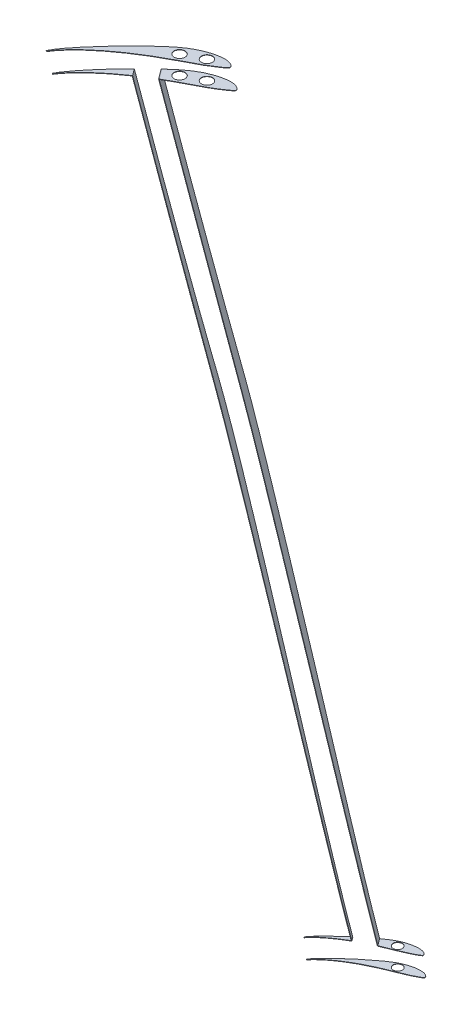
from build123d import *

# Parameters (mm, degrees)
DODANIE_WYCI_GNI_CIE1_DEPTH   = 0.2
DODANIE_WYCI_GNI_CIE2_DEPTH   = 0.2
DODANIE_WYCI_GNI_CIE2_2_DEPTH = 0.2
DODANIE_WYCI_GNI_CIE3_DEPTH   = 0.2
DODANIE_WYCI_GNI_CIE4_DEPTH   = 0.2
DODANIE_WYCI_GNI_CIE5_DEPTH   = 0.2
DODANIE_WYCI_GNI_CIE6_DEPTH   = 0.2
SZKIC7_R                      = 3
WYTNIJ_WYCI_GNI_CIE1_DEPTH    = 12
SZKIC8_R                      = 2.5
WYTNIJ_WYCI_GNI_CIE2_DEPTH    = 12


with BuildPart() as part:
    # Szkic1 → Dodanie-wyciągnięcie1 (new body)
    with BuildSketch(Plane(origin=(0, 700, 0), x_dir=(1, 0, 0), z_dir=(0, 1, 0))):
        with BuildLine():
            Line((-469.151161363, -367.543387188), (-468.754033275, -367.809994573))
            add(Edge.make_bspline(
                [(-468.754033275, -367.809994573), (-468.569338946, -367.494480307), (-468.01155972, -366.60097334), (-466.947424283, -365.122962709), (-465.48428441, -363.306139265), (-463.756300353, -361.359608702), (-461.777561527, -359.314012567), (-459.570064428, -357.20075631), (-457.1553099, -355.05105778), (-454.562230798, -352.890898878), (-451.819856998, -350.745854133), (-448.95930951, -348.639188908), (-446.014833296, -346.589685169), (-443.021070748, -344.613837909), (-440.011073093, -342.727663318), (-437.021704481, -340.938294995), (-434.085422118, -339.25475988), (-431.236177714, -337.680608934), (-428.504481226, -336.21740308), (-425.920558568, -334.863007757), (-423.512367554, -333.611067876), (-421.298114193, -332.459548251), (-419.301271715, -331.358918227), (-417.520296457, -330.293454547), (-415.926643183, -329.300954093), (-414.524688112, -328.390558609), (-413.329960462, -327.570084414), (-412.346413436, -326.860502064), (-411.611043021, -326.237035452), (-411.079804142, -325.773282415), (-410.822961265, -325.253136108), (-411.023332484, -324.771728189), (-411.343648226, -324.327208866), (-411.841838716, -323.895894334), (-412.480332279, -323.506517601), (-413.256323012, -323.178089215), (-414.157747518, -322.922405377), (-415.18757912, -322.771643728), (-416.339089793, -322.728838316), (-417.6073415, -322.779706179), (-418.982209878, -322.936393076), (-420.451786837, -323.202080709), (-422.005498651, -323.578591502), (-423.631299627, -324.073668443), (-425.319415007, -324.683819216), (-427.055948123, -325.414961207), (-428.829361223, -326.269310885), (-430.623405456, -327.264272721), (-432.43901635, -328.399450027), (-434.269608687, -329.697174829), (-436.121612028, -331.150700732), (-438.019015215, -332.722539148), (-439.944328295, -334.414483906), (-441.895976558, -336.205544225), (-443.868637062, -338.078106566), (-445.856001638, -340.009413128), (-447.843745434, -341.981365329), (-449.818738609, -343.973423903), (-451.762014358, -345.973691397), (-453.658579771, -347.968842865), (-455.496647581, -349.945626121), (-457.262175947, -351.893988144), (-458.946910466, -353.800266685), (-460.538876427, -355.654188103), (-462.030647352, -357.4425374), (-463.412826785, -359.154757791), (-464.677262961, -360.78053458), (-465.817166352, -362.309964072), (-466.827364143, -363.733180553), (-467.701923622, -365.042564021), (-468.437355931, -366.229984791), (-468.89927664, -367.054105831), (-469.118218662, -367.478463201), (-469.151161363, -367.543387188)],
                knots=[0.021882554, 0.021882554, 0.021882554, 0.021882554, 0.028864178, 0.04183079, 0.056713807, 0.073341232, 0.091507989, 0.111021837, 0.131661709, 0.153207715, 0.175433402, 0.198110317, 0.221011446, 0.243905882, 0.266573311, 0.288810349, 0.310405036, 0.331177743, 0.350943876, 0.3695564, 0.386864963, 0.402753039, 0.417195876, 0.430379519, 0.442362633, 0.453032156, 0.462284346, 0.470026206, 0.476176645, 0.480649947, 0.483553073, 0.486420689, 0.489953231, 0.494096927, 0.498850588, 0.50419675, 0.510125492, 0.516691031, 0.524011699, 0.532092122, 0.540897921, 0.550403414, 0.560581041, 0.571396483, 0.582828081, 0.594829641, 0.607347037, 0.620384325, 0.633968937, 0.648199967, 0.663193937, 0.678898581, 0.695226562, 0.712113221, 0.729459406, 0.747143117, 0.765009772, 0.782904928, 0.800688045, 0.818242105, 0.835449083, 0.852211621, 0.868429578, 0.884009363, 0.898854951, 0.912881827, 0.92601075, 0.938166771, 0.949289699, 0.959322172, 0.968216949, 0.97594822, 0.977339045, 0.977339045, 0.977339045, 0.977339045], degree=3))
        make_face()
    extrude(amount=DODANIE_WYCI_GNI_CIE1_DEPTH)


with BuildPart() as body_2:
    # Szkic2 → Dodanie-wyciągnięcie2 (new body)
    with BuildSketch(Plane.XZ.offset(-690)):
        with BuildLine():
            Line((-435.154658869, 340.113629547), (-439.167847926, 334.704926055))
            add(Edge.make_bspline(
                [(-439.167847926, 334.704926055), (-438.674884138, 334.248735131), (-437.54704616, 333.219166125), (-435.781759067, 331.66785051), (-433.88435588, 330.096012093), (-432.032352538, 328.642486191), (-430.201760202, 327.344761389), (-428.386149308, 326.209584083), (-426.592105074, 325.214622247), (-424.818691974, 324.360272569), (-423.082158858, 323.629130578), (-421.394043479, 323.018979805), (-419.768242503, 322.523902864), (-418.214530689, 322.147392071), (-416.74495373, 321.881704438), (-415.370085351, 321.72501754), (-414.101833645, 321.674149678), (-412.950322972, 321.71695509), (-411.92049137, 321.867716739), (-411.019066863, 322.123400577), (-410.24307613, 322.451828963), (-409.604582568, 322.841205696), (-409.106392077, 323.272520228), (-408.786076335, 323.717039551), (-408.585705116, 324.19844747), (-408.842547994, 324.718593777), (-409.373786872, 325.182346814), (-410.109157287, 325.805813425), (-411.092704313, 326.515395776), (-412.287431964, 327.335869971), (-413.689387035, 328.246265454), (-415.283040308, 329.238765908), (-417.064015567, 330.304229588), (-419.060858044, 331.404859613), (-421.275111405, 332.556379238), (-423.68330242, 333.808319119), (-426.267225078, 335.162714442), (-428.998921566, 336.625920296), (-431.84816597, 338.200071242), (-433.909500044, 339.381949505), (-435.019864192, 340.034212856), (-435.154658869, 340.113629547)],
                knots=[0.276246459, 0.276246459, 0.276246459, 0.276246459, 0.2896648, 0.306753994, 0.323190791, 0.338883781, 0.353778265, 0.367996193, 0.381641281, 0.394742239, 0.407303314, 0.419267854, 0.430587514, 0.441239623, 0.451188263, 0.460404589, 0.468861723, 0.476523682, 0.483395307, 0.489600448, 0.495195848, 0.500171126, 0.504508001, 0.508205231, 0.511206535, 0.514245006, 0.518926854, 0.525364027, 0.533466814, 0.543150343, 0.554317279, 0.566859048, 0.580657314, 0.595773478, 0.612402258, 0.630517749, 0.649997991, 0.670685624, 0.692426757, 0.715028191, 0.718153736, 0.718153736, 0.718153736, 0.718153736], degree=3))
        make_face()
    extrude(amount=DODANIE_WYCI_GNI_CIE2_DEPTH)

    # Szkic3 → Dodanie-wyciągnięcie3 (add)
    with BuildSketch(Plane(origin=(-295.538450961, -87.183744061, 219.285763923), x_dir=(-0.556130606, -0.164058343, -0.814741437), z_dir=(0.781447989, 0.230526895, -0.579824448))):
        with BuildLine():
            Line((-112.442125967, 394.872681615), (-107.718471353, 395.680653374))
            add(Edge.make_bspline(
                [(-107.718471353, 395.680653374), (-107.995832024, 398.253393679), (-108.238299162, 400.829867367), (-108.67795625, 405.986010422), (-108.874839994, 408.565753226), (-109.417055788, 416.308509628), (-109.714877053, 421.475250205), (-110.239678221, 431.810932285), (-110.465762991, 436.980376597), (-110.875867202, 447.321122325), (-111.059642421, 452.492479146), (-111.577463194, 468.007698082), (-111.877160695, 478.352606755), (-112.483789549, 499.04219693), (-112.79623359, 509.386705314), (-113.507724269, 530.073002441), (-113.904225496, 540.414679246), (-114.797102632, 561.093244077), (-115.292539721, 571.430324858), (-116.143336846, 586.931109411), (-116.44503699, 592.096885696), (-117.100310928, 602.423657951), (-117.453301541, 607.584877215), (-118.245916642, 617.899911535), (-118.683775285, 623.053877509), (-119.469311859, 630.773822903), (-119.752977362, 633.345273179), (-120.388567669, 638.482339913), (-120.739939712, 641.048851858), (-121.149091713, 643.608528228)],
                knots=[0, 0, 0, 0, 0.03125, 0.03125, 0.0625, 0.0625, 0.125, 0.125, 0.1875, 0.1875, 0.25, 0.25, 0.375, 0.375, 0.5, 0.5, 0.625, 0.625, 0.75, 0.75, 0.8125, 0.8125, 0.875, 0.875, 0.9375, 0.9375, 0.96875, 0.96875, 1, 1, 1, 1], degree=3))
            add(Edge.make_bspline(
                [(-121.149091713, 643.608528228), (-122.095771837, 649.531008733), (-123.089876294, 655.445754322), (-125.057115479, 667.278665745), (-126.028548204, 673.197108951), (-127.925338173, 685.041509574), (-128.851842631, 690.967368454), (-130.651895828, 702.826505572), (-131.52564263, 708.759876065), (-134.071818525, 726.57084723), (-135.668556223, 738.45978396), (-138.735293735, 762.253240837), (-140.206473336, 774.157850311), (-141.66354734, 786.064245496)],
                knots=[0, 0, 0, 0, 0.125, 0.125, 0.25, 0.25, 0.375, 0.375, 0.5, 0.5, 0.75, 0.75, 1, 1, 1, 1], degree=3))
            Line((-141.66354734, 786.064245496), (-148.302099459, 784.928734314))
            add(Edge.make_bspline(
                [(-148.302099459, 784.928734314), (-146.832383128, 773.019362902), (-145.358308533, 761.110523026), (-142.37255026, 737.29759311), (-140.860193161, 725.393562292), (-137.781332039, 701.592416698), (-136.214224644, 689.695469489), (-133.0441377, 665.906298442), (-131.444516851, 654.013665882), (-129.847452676, 642.120690825)],
                knots=[0, 0, 0, 0, 0.25, 0.25, 0.5, 0.5, 0.75, 0.75, 1, 1, 1, 1], degree=3))
            add(Edge.make_bspline(
                [(-129.847452676, 642.120690825), (-129.503753749, 639.561242795), (-129.188650323, 636.997967653), (-128.596621984, 631.867485224), (-128.31993079, 629.300222852), (-127.531866207, 621.594041649), (-127.061749034, 616.450630518), (-126.187316499, 606.158828011), (-125.78365027, 601.010008903), (-125.019730162, 590.709286705), (-124.659688805, 585.557284875), (-123.623105696, 570.098505967), (-122.989084596, 559.789213033), (-121.764302264, 539.168017712), (-121.174295808, 528.856069798), (-119.409057697, 497.91993765), (-118.243545309, 477.29518149), (-116.322492612, 446.368224554), (-115.653955933, 436.06115909), (-114.556241661, 420.607638325), (-114.174285055, 415.457643999), (-113.358077566, 405.161497191), (-112.925292657, 400.015170506), (-112.442125967, 394.872681615)],
                knots=[0, 0, 0, 0, 0.03125, 0.03125, 0.0625, 0.0625, 0.125, 0.125, 0.1875, 0.1875, 0.25, 0.25, 0.375, 0.375, 0.5, 0.5, 0.75, 0.75, 0.875, 0.875, 0.9375, 0.9375, 1, 1, 1, 1], degree=3))
        make_face()
    extrude(amount=DODANIE_WYCI_GNI_CIE3_DEPTH)



with BuildPart() as body_3:
    # Szkic2 → Dodanie-wyci_gni_cie2 2 (new body)
    with BuildSketch(Plane.XZ.offset(-690)):
        with BuildLine():
            Line((-466.516777127, 366.755305935), (-466.913905214, 366.488698548))
            add(Edge.make_bspline(
                [(-466.913905214, 366.488698548), (-466.880962514, 366.423774563), (-466.662020492, 365.999417193), (-466.200099782, 365.175296153), (-465.464667474, 363.987875383), (-464.590107995, 362.678491915), (-463.579910203, 361.255275433), (-462.440006812, 359.725845942), (-461.175570637, 358.100069153), (-459.793391203, 356.387848762), (-458.301620279, 354.599499465), (-456.709654318, 352.745578047), (-455.024919798, 350.839299506), (-453.259391433, 348.890937483), (-451.421323622, 346.914154226), (-449.524758209, 344.919002759), (-447.910501795, 343.257403968), (-446.929508181, 342.262846842), (-446.601978671, 341.932309257)],
                knots=[0.787204945, 0.787204945, 0.787204945, 0.787204945, 0.788660611, 0.796752314, 0.806061767, 0.816561955, 0.828203436, 0.840926173, 0.854667168, 0.869347978, 0.88488567, 0.901191786, 0.918165827, 0.935709836, 0.953719006, 0.972091438, 0.990703606, 1, 1, 1, 1], degree=3))
            Line((-446.601978671, 341.932309257), (-443.86934511, 345.615167074))
            add(Edge.make_bspline(
                [(-443.86934511, 345.615167074), (-444.828451589, 346.266480341), (-446.754610912, 347.608477449), (-449.582600849, 349.691165494), (-452.324974648, 351.83621024), (-454.91805375, 353.996369141), (-457.332808278, 356.146067671), (-459.540305377, 358.259323928), (-461.519044203, 360.304920063), (-463.24702826, 362.251450626), (-464.710168134, 364.06827407), (-465.77430357, 365.546284701), (-466.332082797, 366.439791668), (-466.516777127, 366.755305935)],
                knots=[0, 0, 0, 0, 0.023161092, 0.046895208, 0.070157059, 0.092707542, 0.114309649, 0.134733235, 0.153746928, 0.171149526, 0.186726392, 0.200297508, 0.207604617, 0.207604617, 0.207604617, 0.207604617], degree=3))
        make_face()
    extrude(amount=DODANIE_WYCI_GNI_CIE2_2_DEPTH)

    # Szkic4 → Dodanie-wyciągnięcie4 (add)
    with BuildSketch(Plane(origin=(-303.352930853, -89.489013012, 225.084008406), x_dir=(0.556130606, 0.164058343, 0.814741437), z_dir=(-0.781447989, -0.230526895, 0.579824448))):
        with BuildLine():
            Line((108.446658466, 397.959582923), (111.045839487, 397.51499816))
            add(Edge.make_bspline(
                [(111.045839487, 397.51499816), (111.58979421, 402.650382191), (112.05601068, 407.793594665), (112.915080215, 418.085437745), (113.305872608, 423.234759559), (114.412789535, 438.686625286), (115.065386645, 448.99367813), (116.313905542, 469.61138001), (116.907428868, 479.922029793), (118.082241993, 500.544045332), (118.662240544, 510.855488289), (119.841616113, 531.477235249), (120.440536199, 541.787565953), (121.695403243, 562.404874697), (122.350314973, 572.712406625), (123.423819809, 588.165342163), (123.797110403, 593.314949533), (124.589836796, 603.610070519), (125.008988108, 608.755609372), (125.919080095, 619.040318311), (126.409129838, 624.179567436), (127.236645578, 631.880240242), (127.528129305, 634.445743223), (128.155505556, 639.572809476), (128.491109132, 642.134398381), (128.860521569, 644.692987946)],
                knots=[0, 0, 0, 0, 0.0625, 0.0625, 0.125, 0.125, 0.25, 0.25, 0.375, 0.375, 0.5, 0.5, 0.625, 0.625, 0.75, 0.75, 0.8125, 0.8125, 0.875, 0.875, 0.9375, 0.9375, 0.96875, 0.96875, 1, 1, 1, 1], degree=3))
            add(Edge.make_bspline(
                [(128.860521569, 644.692987946), (130.575018089, 656.567771978), (132.292298934, 668.442182604), (135.643978804, 692.202600773), (137.27940195, 704.088562506), (140.451342293, 727.873887776), (141.988954677, 739.772879209), (144.998881272, 763.579280151), (146.472053105, 775.486440486), (147.937926308, 787.39450992)],
                knots=[0, 0, 0, 0, 0.25, 0.25, 0.5, 0.5, 0.75, 0.75, 1, 1, 1, 1], degree=3))
            Line((147.937926308, 787.39450992), (143.417648279, 788.167694518))
            add(Edge.make_bspline(
                [(143.417648279, 788.167694518), (141.963050275, 776.260996647), (140.49239967, 764.3562302), (137.408688945, 740.565180301), (135.795100136, 728.678267924), (132.325170785, 704.941406679), (130.467099897, 693.089983365), (127.44840839, 675.352897183), (126.403853227, 669.447434779), (124.238926554, 657.650159322), (123.118283821, 651.758395097), (121.9710178, 645.871423911)],
                knots=[0, 0, 0, 0, 0.25, 0.25, 0.5, 0.5, 0.75, 0.75, 0.875, 0.875, 1, 1, 1, 1], degree=3))
            add(Edge.make_bspline(
                [(121.9710178, 645.871423911), (121.475535527, 643.328953542), (121.042433033, 640.774399619), (120.259708, 635.654790265), (119.910485012, 633.089523936), (118.952140344, 625.38214774), (118.430318328, 620.227489721), (117.520167335, 609.914551059), (117.13326902, 604.754075032), (116.446958941, 594.42798149), (116.148145568, 589.262328809), (115.344507216, 573.75991691), (114.931253878, 563.417776128), (114.233483239, 542.725928893), (113.950758433, 532.37794103), (113.436173403, 511.680996237), (113.204884908, 501.331852392), (112.710102732, 480.634396271), (112.448415114, 470.285883909), (111.956771623, 454.766575867), (111.776193719, 449.594049436), (111.362961819, 439.250793859), (111.130623024, 434.079636118), (110.583482312, 423.743730723), (110.26970603, 418.578685907), (109.692372304, 410.838833511), (109.481888975, 408.26018736), (109.009484647, 403.106615274), (108.747974655, 400.531659612), (108.446658466, 397.959582923)],
                knots=[0, 0, 0, 0, 0.03125, 0.03125, 0.0625, 0.0625, 0.125, 0.125, 0.1875, 0.1875, 0.25, 0.25, 0.375, 0.375, 0.5, 0.5, 0.625, 0.625, 0.75, 0.75, 0.8125, 0.8125, 0.875, 0.875, 0.9375, 0.9375, 0.96875, 0.96875, 1, 1, 1, 1], degree=3))
        make_face()
    extrude(amount=DODANIE_WYCI_GNI_CIE4_DEPTH)


with BuildPart() as body_4:
    # Szkic5 → Dodanie-wyciągnięcie5 (new body)
    with BuildSketch(Plane.XZ.offset(-300)):
        with BuildLine():
            Line((-367.723499777, 326.620936737), (-367.965351577, 326.4188966))
            add(Edge.make_bspline(
                [(-367.965351577, 326.4188966), (-367.939295152, 326.378624781), (-367.766611838, 326.115648761), (-367.40718925, 325.607466751), (-366.843532329, 324.880073971), (-366.180314976, 324.082348287), (-365.420383088, 323.219376286), (-364.568148768, 322.295742292), (-363.62768086, 321.317554434), (-362.604110155, 320.290834383), (-361.503488334, 319.221779302), (-360.332699316, 318.116659259), (-359.097519286, 316.983621746), (-357.80650203, 315.828573745), (-356.465997019, 314.659898786), (-355.085897303, 313.483216933), (-353.674838973, 312.306399727), (-352.243563583, 311.137145617), (-350.805318217, 309.981944032), (-349.370120515, 308.853348808), (-347.948603047, 307.762232258), (-346.546466438, 306.723071676), (-345.168411478, 305.747041504), (-343.81691557, 304.847787204), (-342.503315217, 304.022928897), (-341.214473839, 303.298682511), (-339.946643169, 302.679911317), (-338.702600112, 302.151529061), (-337.481758999, 301.713860097), (-336.293568044, 301.354381364), (-335.145434553, 301.070845971), (-334.046056599, 300.858419598), (-333.002079463, 300.718717367), (-332.02086267, 300.645836232), (-331.109208997, 300.637853882), (-330.274701932, 300.691865468), (-329.523138866, 300.799215406), (-328.858739016, 300.968922332), (-328.285701877, 301.198534883), (-327.799863209, 301.467173885), (-327.408315002, 301.766279262), (-327.111586561, 302.083201385), (-326.932317408, 302.396525872), (-326.834180643, 302.725760741), (-327.038294751, 303.048890941), (-327.41831924, 303.316173134), (-327.94309718, 303.674047235), (-328.636419937, 304.071256007), (-329.475752701, 304.526581485), (-330.45706099, 305.026555258), (-331.569631209, 305.567125264), (-332.80996633, 306.142602884), (-334.194167214, 306.726256397), (-335.724328155, 307.328281931), (-337.388479734, 307.982750301), (-339.174832879, 308.692248846), (-341.065506295, 309.462867047), (-343.040841884, 310.298085146), (-345.080740932, 311.198981531), (-347.162712518, 312.165567673), (-349.264867849, 313.194164064), (-351.362560941, 314.282635275), (-353.433032441, 315.422763102), (-355.452447438, 316.606125187), (-357.397073929, 317.822773299), (-359.244918075, 319.059606383), (-360.975197194, 320.301866323), (-362.567164123, 321.534521399), (-364.004580825, 322.738597279), (-365.270871578, 323.895030845), (-366.354694269, 324.984714971), (-367.153741598, 325.879875478), (-367.580752591, 326.426920041), (-367.723499777, 326.620936737)],
                knots=[0, 0, 0, 0, 0.001455666, 0.009547369, 0.018856822, 0.02935701, 0.040998491, 0.053721228, 0.067462223, 0.082143033, 0.097680725, 0.113986841, 0.130960882, 0.148504891, 0.166514061, 0.184886493, 0.203498661, 0.222228093, 0.240927693, 0.259435821, 0.277590688, 0.295264604, 0.312353799, 0.328790595, 0.344483585, 0.359378069, 0.373595997, 0.387241085, 0.400342043, 0.412903118, 0.424867658, 0.436187318, 0.446839427, 0.456788068, 0.466004394, 0.474461527, 0.482123486, 0.488995111, 0.495200252, 0.500795653, 0.50577093, 0.510107805, 0.513805035, 0.51680634, 0.51984481, 0.524526658, 0.530963831, 0.539066618, 0.548750147, 0.559917084, 0.572458852, 0.586257119, 0.601373282, 0.618002062, 0.636117554, 0.655597795, 0.676285428, 0.698026562, 0.720627996, 0.743901727, 0.767625915, 0.791587692, 0.815556475, 0.839290591, 0.862552443, 0.885102926, 0.906705032, 0.927128619, 0.946142311, 0.96354491, 0.979121775, 0.992692892, 1, 1, 1, 1], degree=3))
        make_face()
    extrude(amount=DODANIE_WYCI_GNI_CIE5_DEPTH)


with BuildPart() as body_2_1:
    add(body_2.part)

    add(body_3.part)  # Dodanie-wyciągnięcie6 merges body 3
    # Szkic6 → Dodanie-wyciągnięcie6 (add)
    with BuildSketch(Plane(origin=(0, 310, 0), x_dir=(1, 0, 0), z_dir=(0, 1, 0))):
        with BuildLine():
            Line((-368.956587187, -326.803592623), (-368.712959582, -327.006511538))
            add(Edge.make_bspline(
                [(-368.712959582, -327.006511538), (-368.243278094, -326.365091592), (-367.725135669, -325.779445288), (-366.650413767, -324.652389838), (-366.091971716, -324.11312433), (-364.371909059, -322.546814999), (-363.166693044, -321.569945085), (-360.67761251, -319.706721737), (-359.389953084, -318.819976762), (-356.764813237, -317.128652616), (-355.428220618, -316.325555102), (-354.071763057, -315.557655244)],
                knots=[0, 0, 0, 0, 0.125, 0.125, 0.25, 0.25, 0.5, 0.5, 0.75, 0.75, 1, 1, 1, 1], degree=3))
            Line((-354.071763057, -315.557655244), (-355.643040144, -313.439994763))
            add(Edge.make_bspline(
                [(-355.643040144, -313.439994763), (-358.052244646, -315.468518884), (-360.407149696, -317.55733989), (-363.804087072, -320.840948904), (-364.916111542, -321.961013588), (-366.517302336, -323.70478574), (-367.039677114, -324.295801481), (-367.792210424, -325.208989792), (-368.037892941, -325.5178218), (-368.513071286, -326.149395875), (-368.742567777, -326.471160277), (-368.956587187, -326.803592623)],
                knots=[0, 0, 0, 0, 0.5, 0.5, 0.75, 0.75, 0.875, 0.875, 0.9375, 0.9375, 1, 1, 1, 1], degree=3))
        make_face()
        with BuildLine():
            Line((-347.588716009, -307.048466065), (-344.733135655, -310.897023214))
            add(Edge.make_bspline(
                [(-344.733135655, -310.897023214), (-343.140356188, -310.192049073), (-341.532619695, -309.519259451), (-339.109176111, -308.539686345), (-338.299510544, -308.217710307), (-336.679425161, -307.575611552), (-335.867630359, -307.25886742), (-334.657998042, -306.763946658), (-334.256372453, -306.595077995), (-333.458035009, -306.245266753), (-333.061609803, -306.063684523), (-331.879329466, -305.506094059), (-331.097434489, -305.121773345), (-329.94098888, -304.512472731), (-329.557936536, -304.303950782), (-328.801933221, -303.869479199), (-328.433721537, -303.633779227), (-327.992330174, -303.314589939), (-327.907391843, -303.246783154), (-327.796890377, -303.124983157), (-327.763042933, -303.081857742), (-327.707070619, -302.987476476), (-327.685281781, -302.936513912), (-327.667958891, -302.827857015), (-327.673522042, -302.772809497), (-327.698261654, -302.666707276), (-327.717082087, -302.616028022), (-327.780449911, -302.466529748), (-327.834160519, -302.371163046), (-328.019611619, -302.107371822), (-328.17701859, -301.954476856), (-328.511430548, -301.686271377), (-328.691740014, -301.570363702), (-329.261592453, -301.26280363), (-329.663716989, -301.117205525), (-330.287532837, -300.967379936), (-330.499960677, -300.928284509), (-330.924383695, -300.867287042), (-331.136702073, -300.8449607), (-332.198681786, -300.762986959), (-333.049555587, -300.796059234), (-334.752885851, -300.983233127), (-335.587147818, -301.138660394), (-337.230724843, -301.536423176), (-338.039814628, -301.779906597), (-339.236045975, -302.206257838), (-339.63170605, -302.359205894), (-340.41668631, -302.68736974), (-340.80722556, -302.862676625), (-341.959083936, -303.413238259), (-342.700247451, -303.816668657), (-344.140913376, -304.680219863), (-344.843175476, -305.136585419), (-346.23117991, -306.071795827), (-346.913774795, -306.554923574), (-347.588716009, -307.048466065)],
                knots=[0, 0, 0, 0, 0.125, 0.125, 0.1875, 0.1875, 0.25, 0.25, 0.28125, 0.28125, 0.3125, 0.3125, 0.375, 0.375, 0.40625, 0.40625, 0.4375, 0.4375, 0.4453125, 0.4453125, 0.44921875, 0.44921875, 0.453125, 0.453125, 0.45703125, 0.45703125, 0.4609375, 0.4609375, 0.46875, 0.46875, 0.484375, 0.484375, 0.5, 0.5, 0.53125, 0.53125, 0.546875, 0.546875, 0.5625, 0.5625, 0.625, 0.625, 0.6875, 0.6875, 0.75, 0.75, 0.78125, 0.78125, 0.8125, 0.8125, 0.875, 0.875, 0.9375, 0.9375, 1, 1, 1, 1], degree=3))
        make_face()
    extrude(amount=DODANIE_WYCI_GNI_CIE6_DEPTH)


with BuildPart() as wytnij_wyci_gni_cie1_tool:
    # Szkic7 → Wytnij-wyciągnięcie1 (new body)
    with BuildSketch(Plane(origin=(0, 700.2, 0), x_dir=(1, 0, 0), z_dir=(0, 1, 0))):
        with Locations((-421.090050281, -327.725114352)):
            Circle(SZKIC7_R)
        with Locations((-431.039698402, -332.774189517)):
            Circle(SZKIC7_R)
    extrude(amount=-WYTNIJ_WYCI_GNI_CIE1_DEPTH)


with BuildPart() as part_1:
    add(part.part)

    # Wytnij-wyciągnięcie1: cut by wytnij_wyci_gni_cie1_tool
    add(wytnij_wyci_gni_cie1_tool.part, mode=Mode.SUBTRACT)


with BuildPart() as body_2_2:
    add(body_2_1.part)

    # Wytnij-wyciągnięcie1: cut by wytnij_wyci_gni_cie1_tool
    add(wytnij_wyci_gni_cie1_tool.part, mode=Mode.SUBTRACT)


with BuildPart() as wytnij_wyci_gni_cie2_tool:
    # Szkic8 → Wytnij-wyciągnięcie2 (new body)
    with BuildSketch(Plane(origin=(0, 310.2, 0), x_dir=(1, 0, 0), z_dir=(0, 1, 0))):
        with Locations((-339.082998521, -305.429754445)):
            Circle(SZKIC8_R)
    extrude(amount=-WYTNIJ_WYCI_GNI_CIE2_DEPTH)


with BuildPart() as body_2_3:
    add(body_2_2.part)

    # Wytnij-wyciągnięcie2: cut by wytnij_wyci_gni_cie2_tool
    add(wytnij_wyci_gni_cie2_tool.part, mode=Mode.SUBTRACT)


with BuildPart() as body_4_1:
    add(body_4.part)

    # Wytnij-wyciągnięcie2: cut by wytnij_wyci_gni_cie2_tool
    add(wytnij_wyci_gni_cie2_tool.part, mode=Mode.SUBTRACT)


solid = Compound([part_1.part, body_2_3.part, body_4_1.part])
